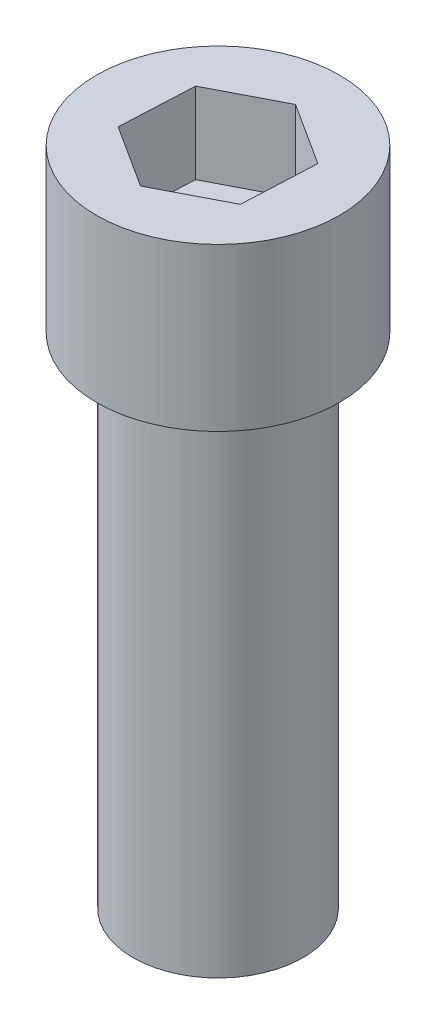
from build123d import *

# Parameters (mm, degrees)
ESBO_O1_R                = 5.25
RESSALTO_EXTRUS_O1_DEPTH = 34.8
ESBO_O2_R                = 7.5
RESSALTO_EXTRUS_O2_DEPTH = 10
CORTE_EXTRUS_O1_DEPTH    = 5
ESBO_O4_R                = 5.25
CORTE_EXTRUS_O2_DEPTH    = 4


with BuildPart() as part:
    # Esboço1 → Ressalto-extrusão1 (new body)
    with BuildSketch(Plane(origin=(0, 0, 0), x_dir=(1, 0, 0), z_dir=(0, 1, 0))):
        Circle(ESBO_O1_R)
    extrude(amount=RESSALTO_EXTRUS_O1_DEPTH)

    # Esboço2 → Ressalto-extrusão2 (add)
    with BuildSketch(Plane(origin=(0, 34.8, 0), x_dir=(1, 0, 0), z_dir=(0, 1, 0))):
        Circle(ESBO_O2_R)
    extrude(amount=RESSALTO_EXTRUS_O2_DEPTH)

    # Esboço3 → Corte-extrusão1 (cut)
    with BuildSketch(Plane(origin=(0, 44.8, 0), x_dir=(1, 0, 0), z_dir=(0, 1, 0))):
        Polygon((0.212546418, 4.56974799), (-3.851244639, 2.468944592), (-4.063791057, -2.100803397), (-0.212546418, -4.56974799), (3.851244639, -2.468944592), (4.063791057, 2.100803397), align=None)
    extrude(amount=-CORTE_EXTRUS_O1_DEPTH, mode=Mode.SUBTRACT)

    # Esboço4 → Corte-extrusão2 (cut)
    with BuildSketch(Plane.XZ):
        Circle(ESBO_O4_R)
    extrude(amount=-CORTE_EXTRUS_O2_DEPTH, mode=Mode.SUBTRACT)


solid = part.part
